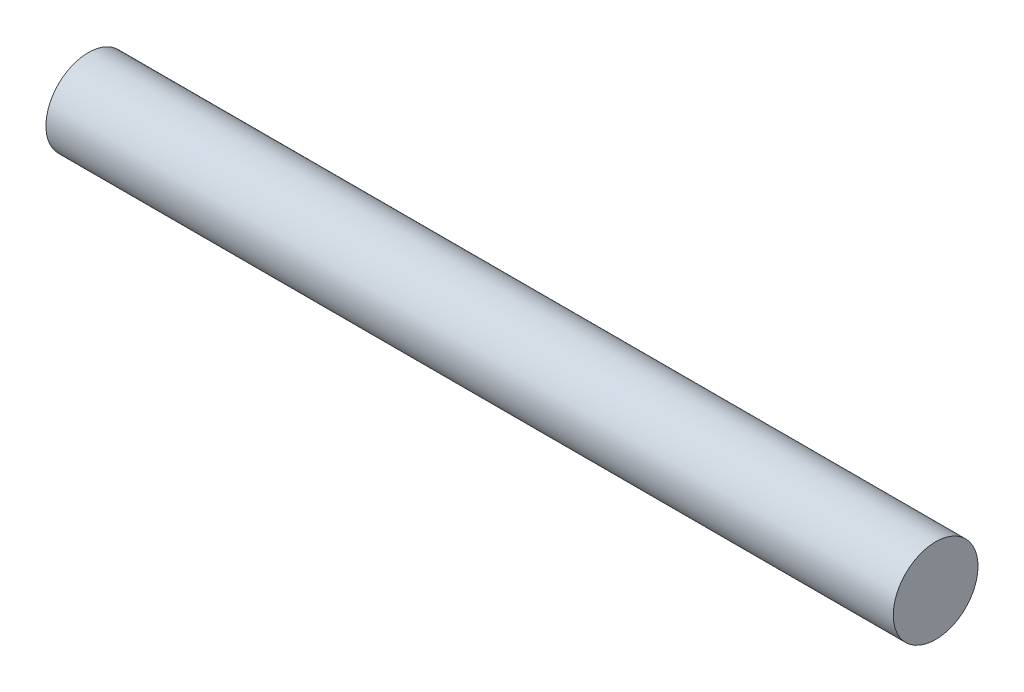
from build123d import *

# Parameters (mm, degrees)
SKETCH1_R           = 0.75
BOSS_EXTRUDE1_DEPTH = 15


with BuildPart() as part:
    # Sketch1 → Boss-Extrude1 (new body)
    with BuildSketch(Plane(origin=(0, 0, 0), x_dir=(0, 0, -1), z_dir=(1, 0, 0))):
        Circle(SKETCH1_R)
    extrude(amount=BOSS_EXTRUDE1_DEPTH)


solid = part.part
